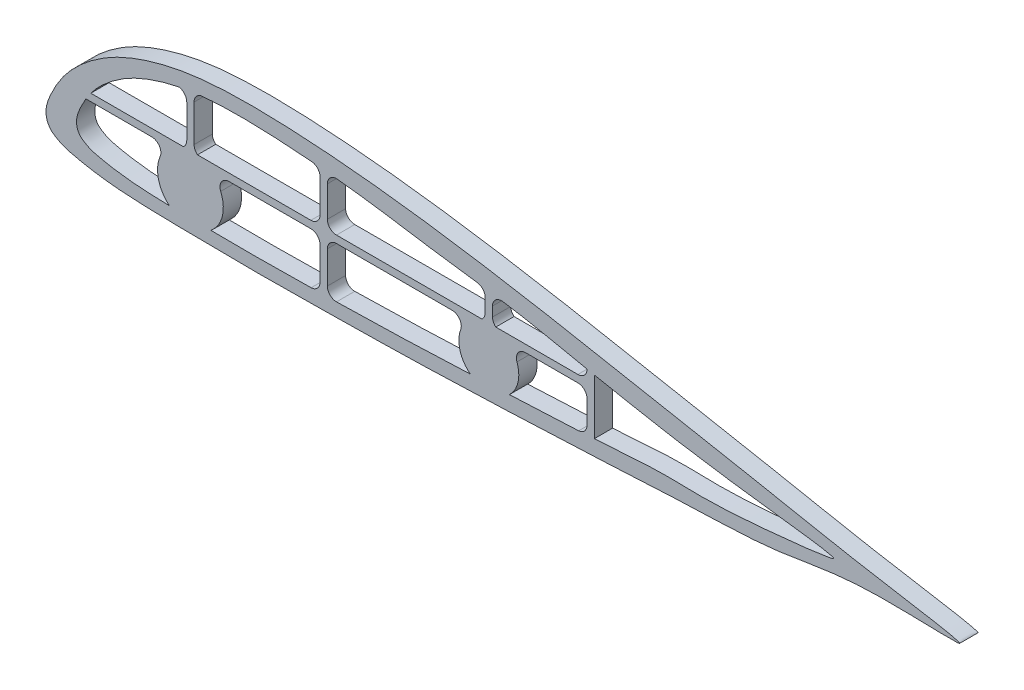
from build123d import *

# Parameters (mm, degrees)
BOSS_EXTRUDE1_DEPTH = 10


with BuildPart() as part:
    # Sketch2 → Boss-Extrude1 (new body)
    with BuildSketch(Plane.XY):
        with BuildLine():
            add(Edge.make_bspline(
                [(249.100340976, -22.300466889), (249.41450338, -21.045289434), (191.219255845, -11.914609165), (151.212895327, -3.533735105), (98.531208702, 6.246748251), (49.293664647, 15.738283166), (-0.81596887, 24.943507567), (-50.736424057, 32.56965713), (-92.492447142, 36.987619279), (-125.880994401, 38.793544278), (-150.943222312, 38.979041464), (-176.239525302, 36.857159422), (-198.136164489, 31.285507167), (-214.769585734, 24.020874576), (-226.428944969, 16.404034942), (-234.763073147, 9.20987659), (-241.3617725, 1.622407729), (-245.447092281, -4.712452003), (-249.344137322, -12.55174904), (-252.273125088, -20.360680833), (-249.287585015, -27.230423186), (-245.259229095, -30.066846383), (-241.095943661, -32.202477902), (-234.274280029, -33.872461481), (-225.957284731, -35.558064096), (-214.270191613, -37.104615753), (-197.586147647, -38.216957675), (-175.900943176, -38.562016502), (-150.901147107, -38.890420569), (-125.898138108, -38.979041464), (-92.566599889, -38.468545323), (-50.876949965, -37.894480852), (-0.931145371, -36.040052426), (49.260698338, -33.945863559), (98.536640201, -30.976934546), (151.351249754, -29.944945838), (189.863775268, -19.939550367), (245.922134572, -23.33741268), (249.069476893, -22.423778591), (249.100340976, -22.300466889)],
                knots=[0, 0, 0, 0, 0.049040866, 0.098081731, 0.147122597, 0.196163463, 0.245116686, 0.293834629, 0.342263553, 0.366385573, 0.390475046, 0.414675268, 0.439565651, 0.455415353, 0.466907824, 0.479711554, 0.487090329, 0.495936907, 0.501323477, 0.512663454, 0.51831006, 0.521365152, 0.526751722, 0.531754914, 0.54158153, 0.551304728, 0.565797224, 0.589894838, 0.613986045, 0.638075566, 0.662166773, 0.710353523, 0.758560308, 0.806785868, 0.855025, 0.903284915, 0.951821054, 0.995182105, 1, 1, 1, 1], degree=3))
        make_face()
        with BuildLine():
            Line((-169.999089523, 24.719103534), (-169.999089523, 4.544223608))
            ThreePointArc((-169.999089523, 4.544223608), (-169.50402262, 2.374989229), (-168.116858406, 0.635321308))
            Line((-168.116858406, 0.635321308), (-106.049387372, 0.635321308))
            ThreePointArc((-106.049387372, 0.635321308), (-102.513853466, 2.099787402), (-101.049387372, 5.635321308))
            Line((-101.049387372, 5.635321308), (-101.049387372, 23.721024894))
            ThreePointArc((-101.049387372, 23.721024894), (-102.23245397, 26.950733768), (-105.221795135, 28.652058365))
            add(Edge.make_bspline(
                [(-105.221795135, 28.652058365), (-108.22475605, 28.904252821), (-117.889842987, 29.647738315), (-134.218668216, 30.544719669), (-151.611475502, 30.669586689), (-162.313237301, 29.966354847), (-166.3332645, 29.537814683)],
                knots=[0.331400831, 0.331400831, 0.331400831, 0.331400831, 0.342283155, 0.366406557, 0.390497409, 0.405098251, 0.405098251, 0.405098251, 0.405098251], degree=3))
            ThreePointArc((-166.3332645, 29.537814683), (-168.978466037, 27.746406386), (-169.999089523, 24.719103534))
        make_face(mode=Mode.SUBTRACT)
        with BuildLine():
            Line((-173.999089523, 22.789540464), (-173.999089523, 4.544223608))
            ThreePointArc((-173.999089523, 4.544223608), (-174.494156426, 2.374989229), (-175.88132064, 0.635321308))
            Line((-175.88132064, 0.635321308), (-226.528828662, 0.635321308))
            add(Edge.make_bspline(
                [(-178.2311722, 27.730218849), (-183.663623867, 26.63491749), (-193.269618364, 23.99068002), (-205.330619848, 18.723087679), (-214.658109814, 12.629607615), (-221.325411735, 6.874282948), (-225.10250415, 2.531219177), (-226.431434046, 0.766078518), (-226.528828662, 0.635321308)],
                knots=[0.419589092, 0.419589092, 0.419589092, 0.419589092, 0.439590826, 0.455441435, 0.466934565, 0.479739029, 0.487118226, 0.487706046, 0.487706046, 0.487706046, 0.487706046], degree=3))
            ThreePointArc((-178.2311722, 27.730218849), (-175.232675326, 26.015772773), (-173.999089523, 22.789540464))
        make_face(mode=Mode.SUBTRACT)
        with BuildLine():
            Line((-229.213265594, -3.364678691), (-193.165100011, -3.364678691))
            ThreePointArc((-193.165100011, -3.364678691), (-188.99481173, -5.606292269), (-188.563793384, -10.32120043))
            ThreePointArc((-188.563793384, -10.32120043), (-189.499620097, -21.575549095), (-183.546712123, -31.172372641))
            add(Edge.make_bspline(
                [(-229.213265594, -3.364678691), (-229.56607116, -3.94894307), (-230.650440623, -5.828230062), (-232.990263157, -10.535017815), (-235.333453368, -16.782163243), (-232.94502131, -22.277957127), (-229.722336573, -24.547095684), (-226.391708229, -26.255600902), (-220.934377309, -27.59158775), (-214.280781174, -28.940069954), (-204.931106189, -30.177310747), (-194.682702999, -30.860585051), (-187.110684985, -31.092638282), (-183.546712123, -31.172372641)],
                knots=[0.493498785, 0.493498785, 0.493498785, 0.493498785, 0.495965311, 0.501352189, 0.512692816, 0.518339744, 0.521395012, 0.52678189, 0.531785369, 0.541612547, 0.551336303, 0.565829629, 0.578711073, 0.578711073, 0.578711073, 0.578711073], degree=3))
        make_face(mode=Mode.SUBTRACT)
        with BuildLine():
            Line((-150.833079034, -3.364678689), (-106.049387371, -3.364678689))
            ThreePointArc((-106.049387371, -3.364678689), (-102.513853465, -4.829144783), (-101.049387371, -8.364678689))
            Line((-101.049387371, -8.364678689), (-101.049387371, -26.25198735))
            ThreePointArc((-101.049387371, -26.25198735), (-102.460927248, -29.733790611), (-105.89856895, -31.249712213))
            add(Edge.make_bspline(
                [(-160.866325259, -31.508990615), (-158.655826483, -31.533626827), (-149.779085747, -31.621747598), (-134.23319998, -31.67656553), (-118.124550479, -31.430925789), (-108.677406982, -31.291649131), (-105.89856895, -31.249712213)],
                knots=[0.606032618, 0.606032618, 0.606032618, 0.606032618, 0.61402121, 0.63811211, 0.662204697, 0.672244436, 0.672244436, 0.672244436, 0.672244436], degree=3))
            ThreePointArc((-160.866325259, -31.508990615), (-154.562976183, -21.834796319), (-155.434385662, -10.321200428))
            ThreePointArc((-155.434385662, -10.321200428), (-155.003367315, -5.606292267), (-150.833079034, -3.364678689))
        make_face(mode=Mode.SUBTRACT)
        with BuildLine():
            Line((-97.049387372, -26.026338985), (-97.049387372, -8.364678692))
            ThreePointArc((-97.049387372, -8.364678692), (-95.584921278, -4.829144786), (-92.049387372, -3.364678692))
            Line((-92.049387372, -3.364678692), (-28.73392905, -3.364678692))
            ThreePointArc((-28.73392905, -3.364678692), (-24.632413488, -5.505033593), (-24.042377499, -10.093650655))
            ThreePointArc((-24.042377499, -10.093650655), (-24.44029657, -20.209406097), (-18.822901654, -28.631503348))
            add(Edge.make_bspline(
                [(-92.049388091, -31.026338991), (-86.108254911, -30.92162783), (-66.833023975, -30.533403195), (-42.501975795, -29.663587132), (-23.957534019, -28.858836788), (-18.822901654, -28.631503348)],
                knots=[0.688924299, 0.688924299, 0.688924299, 0.688924299, 0.710394207, 0.758603753, 0.777109102, 0.777109102, 0.777109102, 0.777109102], degree=3))
            ThreePointArc((-92.049388091, -31.026338991), (-95.584921532, -29.561872638), (-97.049387372, -26.026338985))
        make_face(mode=Mode.SUBTRACT)
        with BuildLine():
            Line((11.43878406, -3.364678692), (40.102863484, -3.364678692))
            ThreePointArc((40.102863484, -3.364678692), (43.638397389, -4.829144786), (45.102863483, -8.364678692))
            Line((45.102863483, -8.364678692), (45.102863483, -20.87421458))
            ThreePointArc((45.102863483, -20.87421458), (43.786313875, -24.255367224), (40.5299862, -25.855937794))
            add(Edge.make_bspline(
                [(2.598632439, -27.673785319), (3.655856629, -27.626908657), (16.240737351, -27.071122716), (28.572440486, -26.561142919), (40.5299862, -25.855937794)],
                knots=[0.802973427, 0.802973427, 0.802973427, 0.802973427, 0.806832075, 0.848975325, 0.848975325, 0.848975325, 0.848975325], degree=3))
            ThreePointArc((2.598632439, -27.673785319), (7.312055668, -19.503308927), (6.745084831, -10.087811751))
            ThreePointArc((6.745084831, -10.087811751), (7.33904838, -5.502482446), (11.43878406, -3.364678692))
        make_face(mode=Mode.SUBTRACT)
        with BuildLine():
            Line((49.102863484, 4.885316094), (49.102863484, -25.314981932))
            add(Edge.make_bspline(
                [(49.102863484, -25.314981932), (62.052073164, -24.447923984), (92.879209306, -21.984699145), (111.439855607, -25.16161349), (176.232534919, -18.162787782), (179.935165554, -16.785293419), (180.019907205, -16.632541808), (180.96463543, -14.929615821), (138.747367769, -10.569366604), (99.484284776, -4.241253233), (101.238717767, -4.96093785), (65.20136027, 1.635231405), (49.102863484, 4.885316094)],
                knots=[0.858907741, 0.858907741, 0.858907741, 0.858907741, 0.903336648, 0.960407262, 0.996040726, 1, 1, 1, 1.044139307, 1.053948042, 1.098087349, 1.147128462, 1.147128462, 1.147128462, 1.147128462], degree=3))
        make_face(mode=Mode.SUBTRACT)
        with BuildLine():
            Line((40.102863484, 0.635321308), (-4.8431815, 0.635321308))
            ThreePointArc((-4.8431815, 0.635321308), (-6.175989703, 2.357590652), (-6.650248643, 4.48307127))
            Line((-6.650248643, 4.48307127), (-6.650248643, 9.69188922))
            ThreePointArc((-6.650248643, 9.69188922), (-4.90625334, 13.486415616), (-0.890875475, 14.633887095))
            add(Edge.make_bspline(
                [(45.102446258, 5.699859909), (30.777193197, 8.639712171), (16.280433389, 11.886828416), (1.518169323, 14.263719808), (-0.890875475, 14.633887095)],
                knots=[0.151250521, 0.151250521, 0.151250521, 0.151250521, 0.196174697, 0.204914608, 0.204914608, 0.204914608, 0.204914608], degree=3))
            ThreePointArc((45.102446258, 5.699859909), (43.661141626, 2.122679598), (40.102863484, 0.635321308))
        make_face(mode=Mode.SUBTRACT)
        with BuildLine():
            Line((-10.654088413, 11.691587752), (-10.654088413, 4.458080764))
            ThreePointArc((-10.654088413, 4.458080764), (-11.120102609, 2.350244733), (-12.431277506, 0.635321308))
            Line((-12.431277506, 0.635321308), (-92.049387372, 0.635321308))
            ThreePointArc((-92.049387372, 0.635321308), (-95.584921278, 2.099787402), (-97.049387372, 5.635321308))
            Line((-97.049387372, 5.635321308), (-97.049387372, 22.407527869))
            ThreePointArc((-97.049387372, 22.407527869), (-95.584921287, 25.943061766), (-92.049387398, 27.40752787))
            add(Edge.make_bspline(
                [(-14.983364555, 16.646392003), (-21.411015565, 17.516492748), (-41.335786931, 20.10294128), (-66.76932187, 24.463945651), (-86.096667733, 26.78155439), (-92.049387398, 27.40752787)],
                knots=[0.221910701, 0.221910701, 0.221910701, 0.221910701, 0.245130724, 0.293851458, 0.315472745, 0.315472745, 0.315472745, 0.315472745], degree=3))
            ThreePointArc((-14.983364555, 16.646392003), (-11.8888789, 14.981447194), (-10.654088413, 11.691587752))
        make_face(mode=Mode.SUBTRACT)
    extrude(amount=BOSS_EXTRUDE1_DEPTH)


solid = part.part
